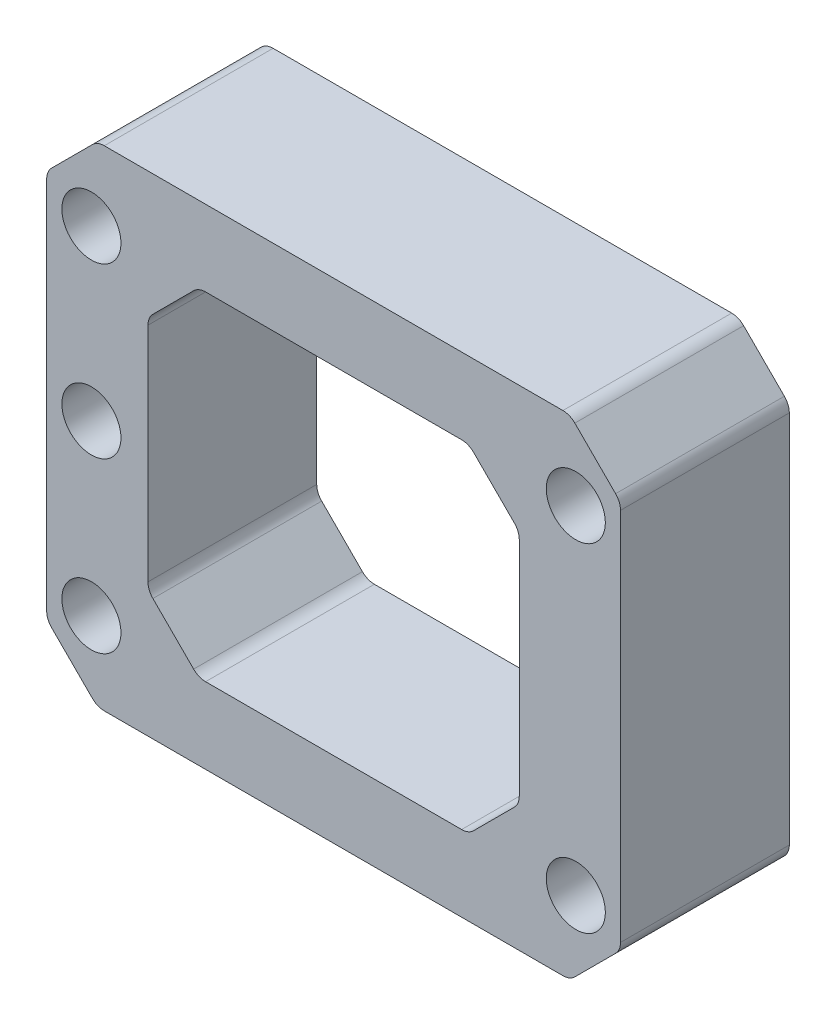
from build123d import *

# Parameters (mm, degrees)
SKETCH_1_W          = 34
SKETCH_1_H          = 29
SKETCH_1_R          = 1.75
EXTRUDE_1_DEPTH     = 10
CHAMFER_1_SIZE      = 3
CUT_EXTRUDE_1_DEPTH = 11
FILLET_1_R          = 1


with BuildPart() as part:
    # 草图1 → 凸台-拉伸1 (new body)
    with BuildSketch(Plane.XY):
        Rectangle(SKETCH_1_W, SKETCH_1_H)
        with Locations((-14.35, -10)):
            Circle(SKETCH_1_R, mode=Mode.SUBTRACT)
        with Locations((-14.35, 10)):
            Circle(SKETCH_1_R, mode=Mode.SUBTRACT)
        with Locations((14.35, 10)):
            Circle(SKETCH_1_R, mode=Mode.SUBTRACT)
        with Locations((14.35, -10)):
            Circle(SKETCH_1_R, mode=Mode.SUBTRACT)
        with Locations((-14.35, 0)):
            Circle(SKETCH_1_R, mode=Mode.SUBTRACT)
    extrude(amount=EXTRUDE_1_DEPTH)

    # 倒角1
    chamfer_1_edges = [part.edges().sort_by_distance(p)[0] for p in [
        (17, -14.5, 5),
        (-17, -14.5, 5),
        (-17, 14.5, 5),
        (17, 14.5, 5),
    ]]
    chamfer(chamfer_1_edges, length=CHAMFER_1_SIZE)

    # 草图2 → 切除-拉伸1 (cut, through all)
    with BuildSketch(Plane.XY.offset(10)):
        Polygon((-11, 7), (-8, 10), (8, 10), (11, 7), (11, -7), (8, -10), (-8, -10), (-11, -7), align=None)
    extrude(amount=-CUT_EXTRUDE_1_DEPTH, mode=Mode.SUBTRACT)

    # 圆角1
    fillet_1_edges = [part.edges().sort_by_distance(p)[0] for p in [
        (17, 11.5, 5),
        (17, -11.5, 5),
        (-14, -14.5, 5),
        (14, -14.5, 5),
        (-14, 14.5, 5),
        (14, 14.5, 5),
        (-17, 11.5, 5),
        (-17, -11.5, 5),
        (-8, 10, 5),
        (8, 10, 5),
        (11, 7, 5),
        (11, -7, 5),
        (8, -10, 5),
        (-8, -10, 5),
        (-11, -7, 5),
        (-11, 7, 5),
    ]]
    fillet(fillet_1_edges, radius=FILLET_1_R)


solid = part.part
